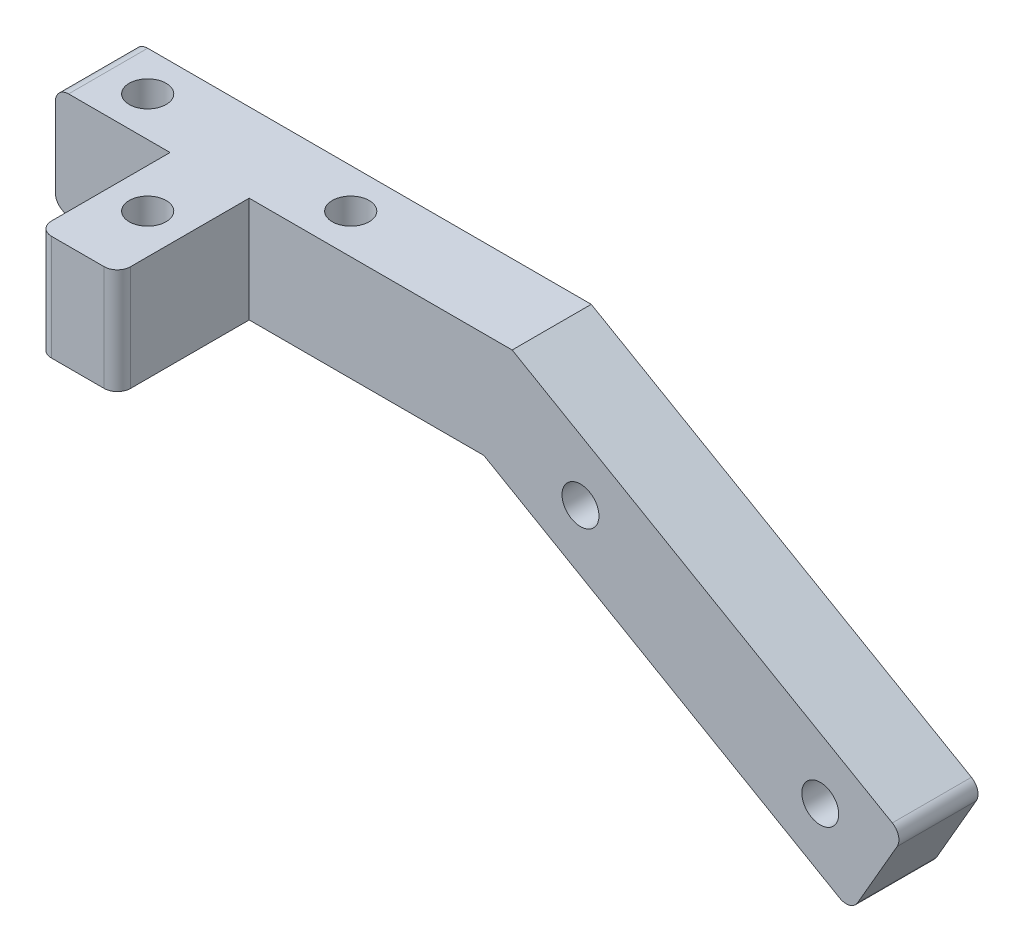
from build123d import *

# Parameters (mm, degrees)
SKETCH1_R           = 1.778
BOSS_EXTRUDE1_DEPTH = 7.62
SKETCH2_R           = 1.778
CUT_EXTRUDE1_DEPTH  = 10.16
SKETCH3_W           = 7.62
SKETCH3_H           = 12.7
SKETCH3_R           = 1.778
BOSS_EXTRUDE2_DEPTH = 10.16
FILLET1_R           = 1.27


with BuildPart() as part:
    # Sketch1 → Boss-Extrude1 (new body)
    with BuildSketch(Plane.XY):
        Polygon((0, 0), (0, 10.16), (43.997363795, 10.16), (81.714794759, -11.61616892), (76.634794759, -20.414987023), (41.275, 0), align=None)
        with Locations((50.578635926, 0.494422029)):
            Circle(SKETCH1_R, mode=Mode.SUBTRACT)
        with Locations((73.675533445, -12.840577971)):
            Circle(SKETCH1_R, mode=Mode.SUBTRACT)
    extrude(amount=BOSS_EXTRUDE1_DEPTH)

    # Sketch2 → Cut-Extrude1 (cut)
    with BuildSketch(Plane(origin=(0, 10.16, 0), x_dir=(1, 0, 0), z_dir=(0, 1, 0))):
        with Locations((5.08, -3.81)):
            Circle(SKETCH2_R)
        with Locations((24.638, -3.81)):
            Circle(SKETCH2_R)
    extrude(amount=-CUT_EXTRUDE1_DEPTH, mode=Mode.SUBTRACT)

    # Sketch3 → Boss-Extrude2 (add)
    with BuildSketch(Plane(origin=(0, 10.16, 0), x_dir=(1, 0, 0), z_dir=(0, 1, 0))):
        with Locations((14.859, -13.97)):
            Rectangle(SKETCH3_W, SKETCH3_H)
        with Locations((14.859, -13.589)):
            Circle(SKETCH3_R, mode=Mode.SUBTRACT)
    extrude(amount=-BOSS_EXTRUDE2_DEPTH)

    # Fillet1
    fillet1_edges = [part.edges().sort_by_distance(p)[0] for p in [
        (0, 0, 3.81),
        (0, 10.16, 3.81),
        (81.714794759, -11.61616892, 3.81),
        (76.634794759, -20.414987023, 3.81),
        (11.049, 5.08, 20.32),
        (18.669, 5.08, 20.32),
    ]]
    fillet(fillet1_edges, radius=FILLET1_R)


solid = part.part
